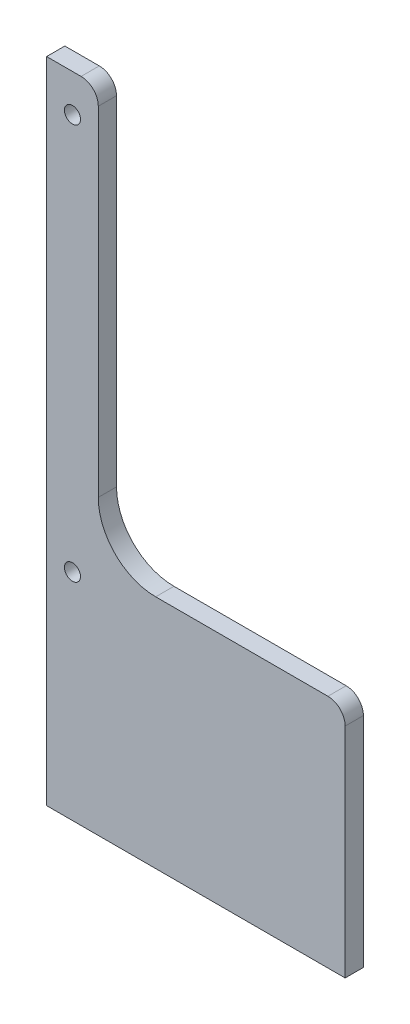
from build123d import *

# Parameters (mm, degrees)
SKETCH1_R           = 1.4
BOSS_EXTRUDE1_DEPTH = 3.175
FILLET1_R           = 10
FILLET2_R           = 3


with BuildPart() as part:
    # Sketch1 → Boss-Extrude1 (new body)
    with BuildSketch(Plane.XY):
        Polygon((9, 9), (9, 81), (0, 81), (0, -32), (52, -32), (52, 9), align=None)
        with Locations((4.5, 5.5)):
            Circle(SKETCH1_R, mode=Mode.SUBTRACT)
        with Locations((4.5, 74.47)):
            Circle(SKETCH1_R, mode=Mode.SUBTRACT)
    extrude(amount=BOSS_EXTRUDE1_DEPTH)

    # Fillet1
    fillet1_edges = [part.edges().sort_by_distance(p)[0] for p in [
        (9, 9, 1.5875),
    ]]
    fillet(fillet1_edges, radius=FILLET1_R)

    # Fillet2
    fillet2_edges = [part.edges().sort_by_distance(p)[0] for p in [
        (9, 81, 1.5875),
        (52, 9, 1.5875),
    ]]
    fillet(fillet2_edges, radius=FILLET2_R)


solid = part.part
